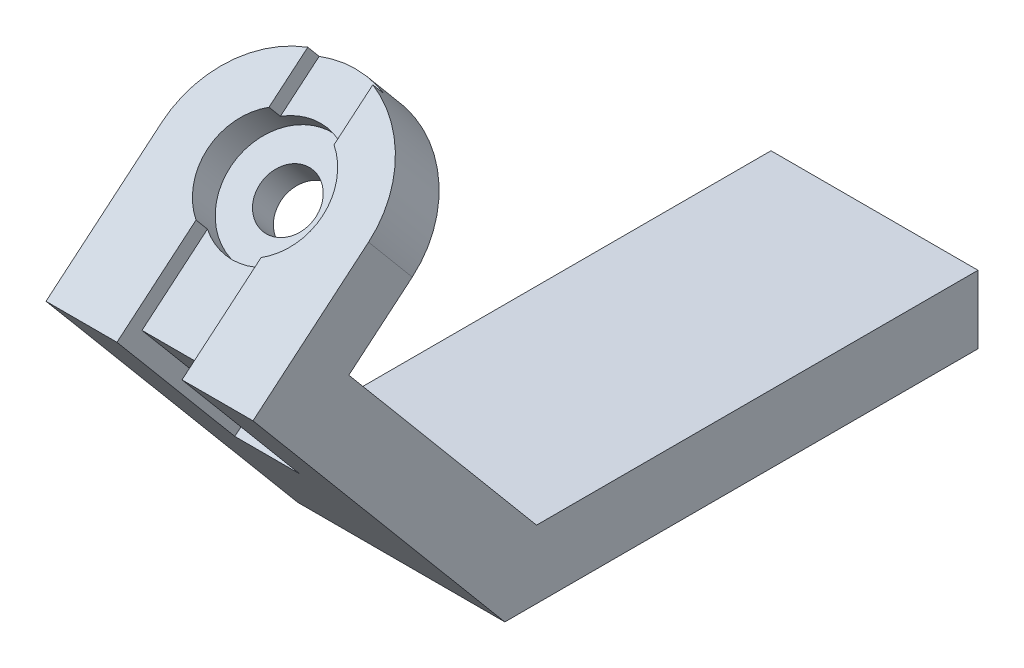
from build123d import *

# Parameters (mm, degrees)
BOSS_EXTRUDE1_DEPTH = 70
BOSS_EXTRUDE2_DEPTH = 23
SKETCH3_3_R         = 9.5
CUT_EXTRUDE1_DEPTH  = 23
SKETCH3_4_R         = 19.5
SKETCH3_4_R_2       = 9.5
CUT_EXTRUDE2_DEPTH  = 12
SKETCH4_W           = 22
SKETCH4_H           = 92.60205789
CUT_EXTRUDE3_DEPTH  = 6
SKETCH5_W           = 22
SKETCH5_H           = 56
CUT_EXTRUDE4_DEPTH  = 6


with BuildPart() as part:
    # Sketch1 → Boss-Extrude1 (new body)
    with BuildSketch(Plane(origin=(0, 0, 0), x_dir=(0, 0, -1), z_dir=(1, 0, 0))):
        Polygon((0, 0), (-149.274923862, 0), (-212.764789027, 75.664274903), (-191.31554462, 93.662327975), (-206.099659643, 111.281350166), (-245.167926242, 78.499182072), (-160, -23), (0, -23), align=None)
    extrude(amount=-BOSS_EXTRUDE1_DEPTH)

    # Sketch3 → Boss-Extrude2 (add)
    with BuildSketch(Plane(origin=(0, 166.78684827, 139.950782869), x_dir=(1, 0, 0), z_dir=(0, 0.7660444431189739, 0.6427876096865442))):
        with BuildLine():
            ThreePointArc((0, -86.351225922), (-35, -51.351225922), (-70, -86.351225922))
            Line((-70, -86.351225922), (-54.5, -86.351225922))
            ThreePointArc((-54.5, -86.351225922), (-35, -105.851225922), (-15.5, -86.351225922))
            Line((-15.5, -86.351225922), (0, -86.351225922))
        make_face()
    extrude(amount=-BOSS_EXTRUDE2_DEPTH)

    # Sketch3_3 → Cut-Extrude1 (cut)
    with BuildSketch(Plane(origin=(0, 166.78684827, 139.950782869), x_dir=(1, 0, 0), z_dir=(0, 0.7660444431189739, 0.6427876096865442))):
        with Locations((-35, -86.351225922)):
            Circle(SKETCH3_3_R)
    extrude(amount=-CUT_EXTRUDE1_DEPTH, mode=Mode.SUBTRACT)

    # Sketch3_4 → Cut-Extrude2 (cut)
    with BuildSketch(Plane(origin=(0, 166.78684827, 139.950782869), x_dir=(1, 0, 0), z_dir=(0, 0.7660444431189739, 0.6427876096865442))):
        with Locations((-35, -86.351225922)):
            Circle(SKETCH3_4_R)
        with Locations((-35, -86.351225922)):
            Circle(SKETCH3_4_R_2, mode=Mode.SUBTRACT)
    extrude(amount=-CUT_EXTRUDE2_DEPTH, mode=Mode.SUBTRACT)

    # Sketch4 → Cut-Extrude3 (cut)
    with BuildSketch(Plane(origin=(0, 166.78684827, 139.950782869), x_dir=(1, 0, 0), z_dir=(0, 0.7660444431189739, 0.6427876096865442))):
        with Locations((-35, -91.050196977)):
            Rectangle(SKETCH4_W, SKETCH4_H)
    extrude(amount=-CUT_EXTRUDE3_DEPTH, mode=Mode.SUBTRACT)

    # Sketch5 → Cut-Extrude4 (cut)
    with BuildSketch(Plane(origin=(0, -88.287666198, 105.217143373), x_dir=(1, 0, 0), z_dir=(0, -0.6427876096865438, 0.7660444431189745))):
        with Locations((-35, 183.724767497)):
            Rectangle(SKETCH5_W, SKETCH5_H)
    extrude(amount=-CUT_EXTRUDE4_DEPTH, mode=Mode.SUBTRACT)


solid = part.part
